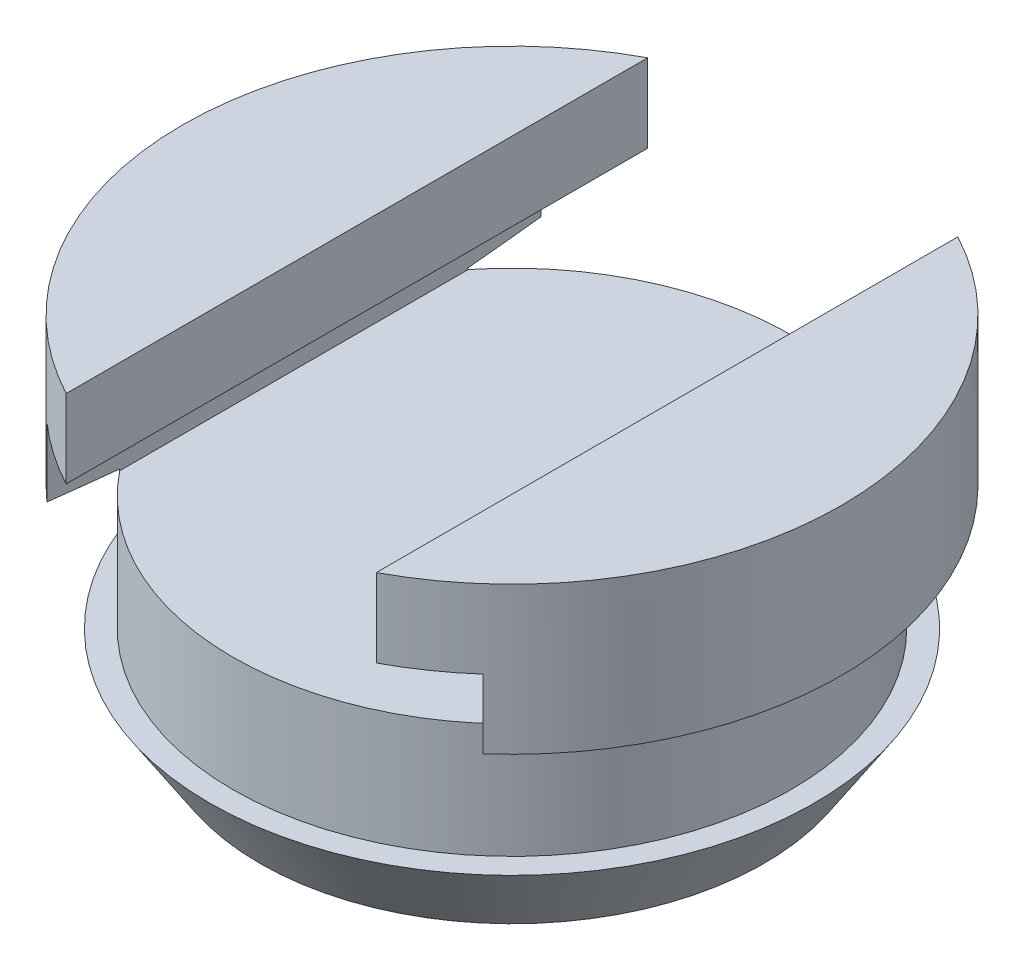
from build123d import *

# Parameters (mm, degrees)
CUT_EXTRUDE1_DEPTH = 19.05


with BuildPart() as part:
    # Sketch1 → Revolve1 (revolve)
    with BuildSketch(Plane.XY, mode=Mode.PRIVATE) as revolve1_sk:
        Polygon((0, 0), (-8.255, 0), (-9.906, 2.54), (-9.144, 2.54), (-9.144, 6.35), (-10.795, 6.604), (-10.795, 11.43), (0, 11.43), align=None)
    revolve(revolve1_sk.sketch.rotate(Axis((0, 11.43, 0), (0, -1, 0)), 270), axis=Axis((0, 11.43, 0), (0, -1, 0)))  # turned: the seam where the file's is

    # Sketch2 → Cut-Extrude1 (cut, symmetric)
    with BuildSketch(Plane.XY):
        Polygon((7.14375, 6.298580206), (-7.14375, 6.298580206), (-7.14375, 8.863980206), (-5.08, 8.863980206), (-5.08, 11.43), (5.08, 11.43), (5.08, 8.863980206), (7.14375, 8.863980206), align=None)
    extrude(amount=CUT_EXTRUDE1_DEPTH, both=True, mode=Mode.SUBTRACT)


solid = part.part
